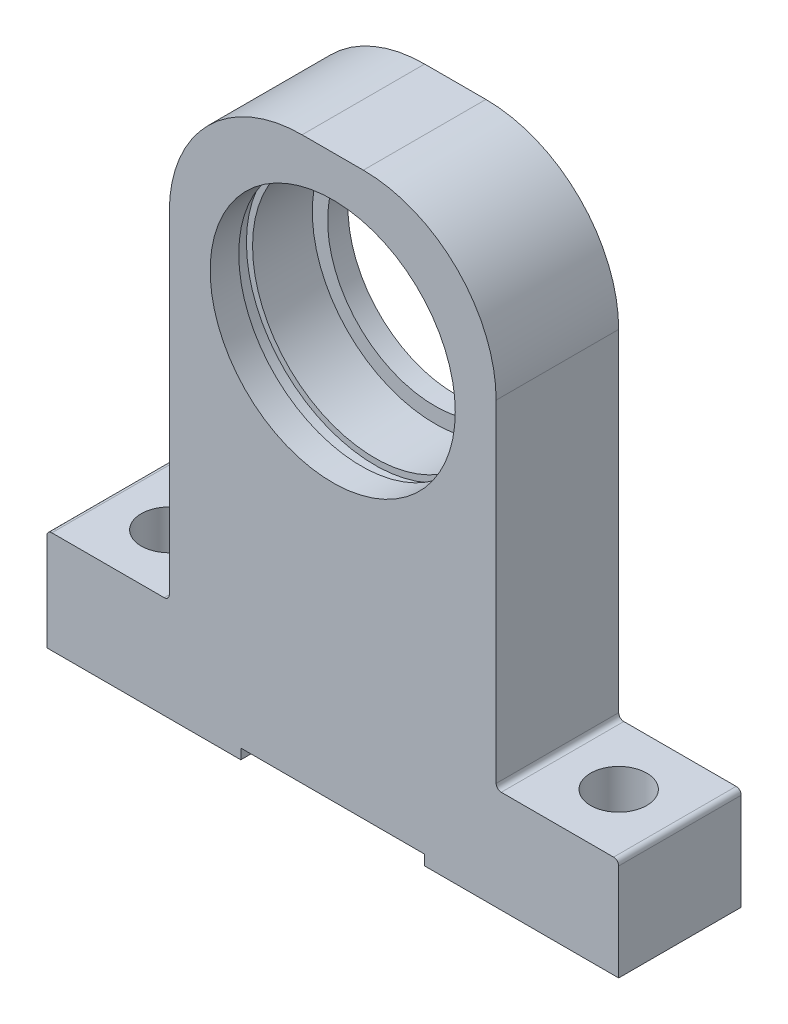
from build123d import *

# Parameters (mm, degrees)
SKETCH1_R           = 10.5
BOSS_EXTRUDE1_DEPTH = 12
CUT_EXTRUDE1_DEPTH  = 13
BOSS_EXTRUDE2_DEPTH = 12
CUT_EXTRUDE2_DEPTH  = 13
SKETCH5_R           = 2.75
CUT_EXTRUDE3_DEPTH  = 11
SKETCH7_R           = 12
CUT_EXTRUDE4_DEPTH  = 10
SKETCH10_W          = 18
SKETCH10_H          = 1
CUT_EXTRUDE5_DEPTH  = 13
SKETCH11_W          = 1.35
SKETCH11_H          = 0.6


with BuildPart() as part:
    # Sketch1 → Boss-Extrude1 (new body)
    with BuildSketch(Plane.XY):
        Polygon((-28, -40), (28, -40), (28, -30), (16, -30), (16, 16), (-16, 16), (-16, -30), (-28, -30), align=None)
        Circle(SKETCH1_R, mode=Mode.SUBTRACT)
    extrude(amount=BOSS_EXTRUDE1_DEPTH)

    # Sketch2 → Cut-Extrude1 (cut, through all)
    with BuildSketch(Plane.XY):
        with BuildLine():
            Line((3, 16), (16, 16))
            Line((16, 16), (16, 3))
            ThreePointArc((16, 3), (12.192388155, 12.192388155), (3, 16))
        make_face()
        with BuildLine():
            Line((-3, 16), (-16, 16))
            Line((-16, 16), (-16, 3))
            ThreePointArc((-16, 3), (-12.192388155, 12.192388155), (-3, 16))
        make_face()
    extrude(amount=CUT_EXTRUDE1_DEPTH, mode=Mode.SUBTRACT)

    # Sketch3 → Boss-Extrude2 (add, through all)
    with BuildSketch(Plane.XY):
        with BuildLine():
            Line((16, -29.5), (16, -30))
            Line((16, -30), (16.5, -30))
            ThreePointArc((16.5, -30), (16.146446609, -29.853553391), (16, -29.5))
        make_face()
        with BuildLine():
            Line((-16, -29.5), (-16, -30))
            Line((-16, -30), (-16.5, -30))
            ThreePointArc((-16.5, -30), (-16.146446609, -29.853553391), (-16, -29.5))
        make_face()
    extrude(amount=BOSS_EXTRUDE2_DEPTH)

    # Sketch4 → Cut-Extrude2 (cut, through all)
    with BuildSketch(Plane.XY):
        with BuildLine():
            Line((-27.5, -30), (-28, -30))
            Line((-28, -30), (-28, -30.5))
            ThreePointArc((-28, -30.5), (-27.853553391, -30.146446609), (-27.5, -30))
        make_face()
        with BuildLine():
            Line((27.5, -30), (28, -30))
            Line((28, -30), (28, -30.5))
            ThreePointArc((28, -30.5), (27.853553391, -30.146446609), (27.5, -30))
        make_face()
    extrude(amount=CUT_EXTRUDE2_DEPTH, mode=Mode.SUBTRACT)

    # Sketch5 → Cut-Extrude3 (cut, through all)
    with BuildSketch(Plane(origin=(0, -30, 0), x_dir=(1, 0, 0), z_dir=(0, 1, 0))):
        with Locations((-22, -6)):
            Circle(SKETCH5_R)
        with Locations((22, -6)):
            Circle(SKETCH5_R)
    extrude(amount=-CUT_EXTRUDE3_DEPTH, mode=Mode.SUBTRACT)

    # Sketch7 → Cut-Extrude4 (cut)
    with BuildSketch(Plane.XY.offset(12)):
        Circle(SKETCH7_R)
    extrude(amount=-CUT_EXTRUDE4_DEPTH, mode=Mode.SUBTRACT)

    # Sketch10 → Cut-Extrude5 (cut, through all)
    with BuildSketch(Plane.XY.offset(12)):
        with Locations((0, -39.5)):
            Rectangle(SKETCH10_W, SKETCH10_H)
    extrude(amount=-CUT_EXTRUDE5_DEPTH, mode=Mode.SUBTRACT)

    # Sketch11 → Cut-Revolve1 (revolve, cut)
    with BuildSketch(Plane(origin=(0, 0, 0), x_dir=(0, 0, -1), z_dir=(1, 0, 0))):
        with Locations((-8.525, 12.3)):
            Rectangle(SKETCH11_W, SKETCH11_H)
    revolve(axis=Axis((0, 0, -88.99), (0, 0, 1)), mode=Mode.SUBTRACT)


solid = part.part
